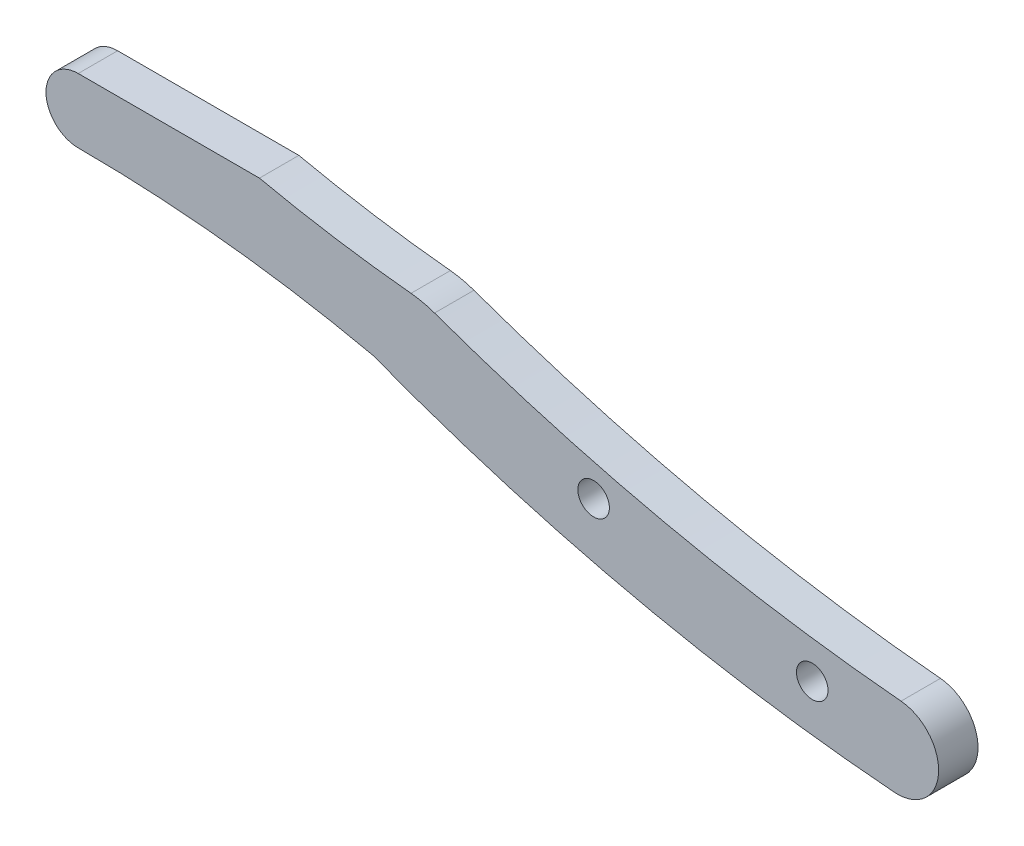
from build123d import *

# Parameters (mm, degrees)
SKETCH3_R           = 1.6
BOSS_EXTRUDE1_DEPTH = 4


with BuildPart() as part:
    # Sketch3 → Boss-Extrude1 (new body)
    with BuildSketch(Plane(origin=(20.494506969, 51.628779219, -66.172927913), x_dir=(1, 0, 0), z_dir=(0, 0, 1))):
        with BuildLine():
            Line((-95, -35.45), (-76.606413565, -35.45))
            ThreePointArc((-76.606413565, -35.45), (-68.94960795, -36.890649791), (-61.222089264, -37.884429946))
            ThreePointArc((-61.222089264, -37.884429946), (-60.011397218, -38.080084438), (-58.833759818, -38.42246736))
            ThreePointArc((-58.833759818, -38.42246736), (-35.490101097, -45.151223745), (-11.481033396, -48.861645973))
            ThreePointArc((-11.481033396, -48.861645973), (-7.68167997, -53.388127631), (-12.188640475, -57.210617614))
            ThreePointArc((-12.188640475, -57.210617614), (-39.092131211, -53.124111692), (-65.141573254, -45.254936785))
            ThreePointArc((-65.141573254, -45.254936785), (-79.981953338, -42.810785721), (-95, -41.992843223))
            ThreePointArc((-95, -41.992843223), (-98.271421612, -38.721421612), (-95, -35.45))
        make_face()
        with Locations((-42.686731091, -46.672569756)):
            Circle(SKETCH3_R, mode=Mode.SUBTRACT)
        with Locations((-20.494506969, -51.628779219)):
            Circle(SKETCH3_R, mode=Mode.SUBTRACT)
    extrude(amount=BOSS_EXTRUDE1_DEPTH)


solid = part.part
